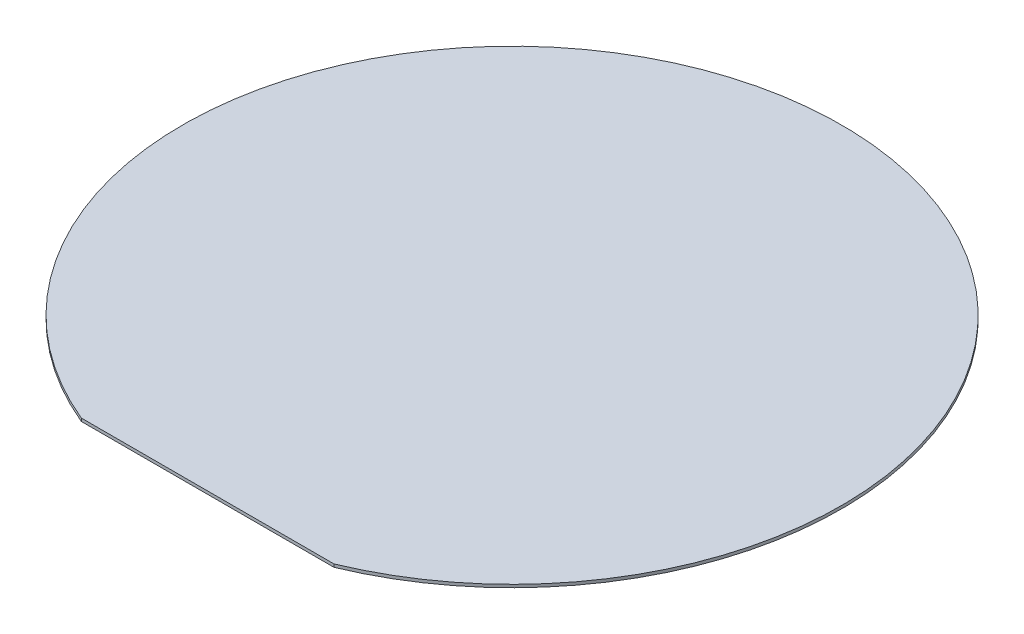
from build123d import *

# Parameters (mm, degrees)
SKETCH1_R           = 75
BOSS_EXTRUDE1_DEPTH = 0.675
SKETCH2_W           = 57.5
SKETCH2_H           = 28.23011143
CUT_EXTRUDE1_DEPTH  = 0.675


with BuildPart() as part:
    # Sketch1 → Boss-Extrude1 (new body)
    with BuildSketch(Plane(origin=(0, 0, 0), x_dir=(1, 0, 0), z_dir=(0, 1, 0))):
        Circle(SKETCH1_R)
    extrude(amount=BOSS_EXTRUDE1_DEPTH)

    # Sketch2 → Cut-Extrude1 (cut)
    with BuildSketch(Plane(origin=(0, 0.675, 0), x_dir=(1, 0, 0), z_dir=(0, 1, 0))):
        with Locations((0, -83.385810727)):
            Rectangle(SKETCH2_W, SKETCH2_H)
    extrude(amount=-CUT_EXTRUDE1_DEPTH, mode=Mode.SUBTRACT)


solid = part.part
